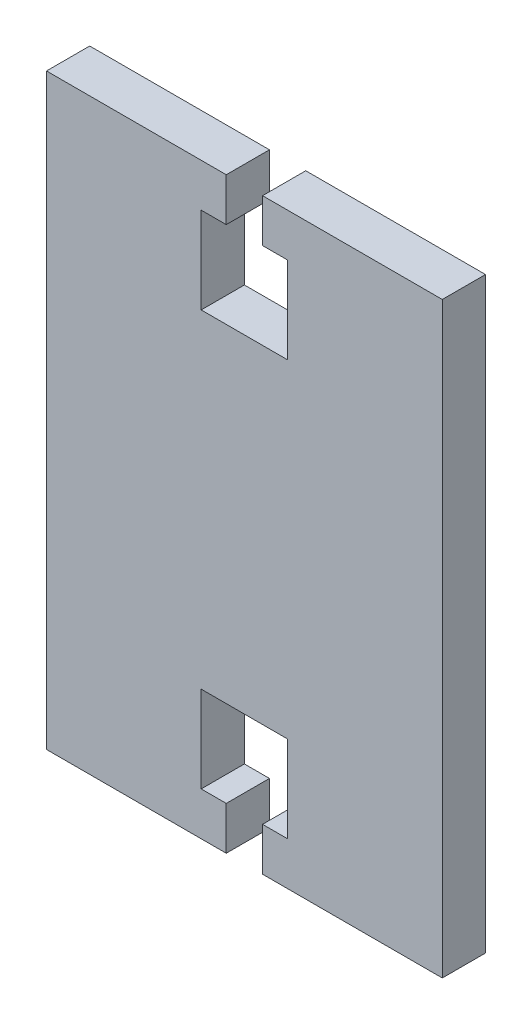
from build123d import *

# Parameters (mm, degrees)
SKETCH1_W           = 45.8
SKETCH1_H           = 68
BOSS_EXTRUDE1_DEPTH = 5
CUT_EXTRUDE1_DEPTH  = 5


with BuildPart() as part:
    # Sketch1 → Boss-Extrude1 (new body)
    with BuildSketch(Plane.XY):
        Rectangle(SKETCH1_W, SKETCH1_H)
    extrude(amount=BOSS_EXTRUDE1_DEPTH)

    # Sketch2 → Cut-Extrude1 (cut)
    with BuildSketch(Plane.XY.offset(5)):
        Polygon((-2.1, 34), (2.1, 34), (2.1, 29), (5, 29), (5, 19), (-5, 19), (-5, 29), (-2.1, 29), align=None)
        Polygon((-2.1, -34), (-2.1, -29), (-5, -29), (-5, -19), (5, -19), (5, -29), (2.1, -29), (2.1, -34), align=None)
    extrude(amount=-CUT_EXTRUDE1_DEPTH, mode=Mode.SUBTRACT)


solid = part.part
